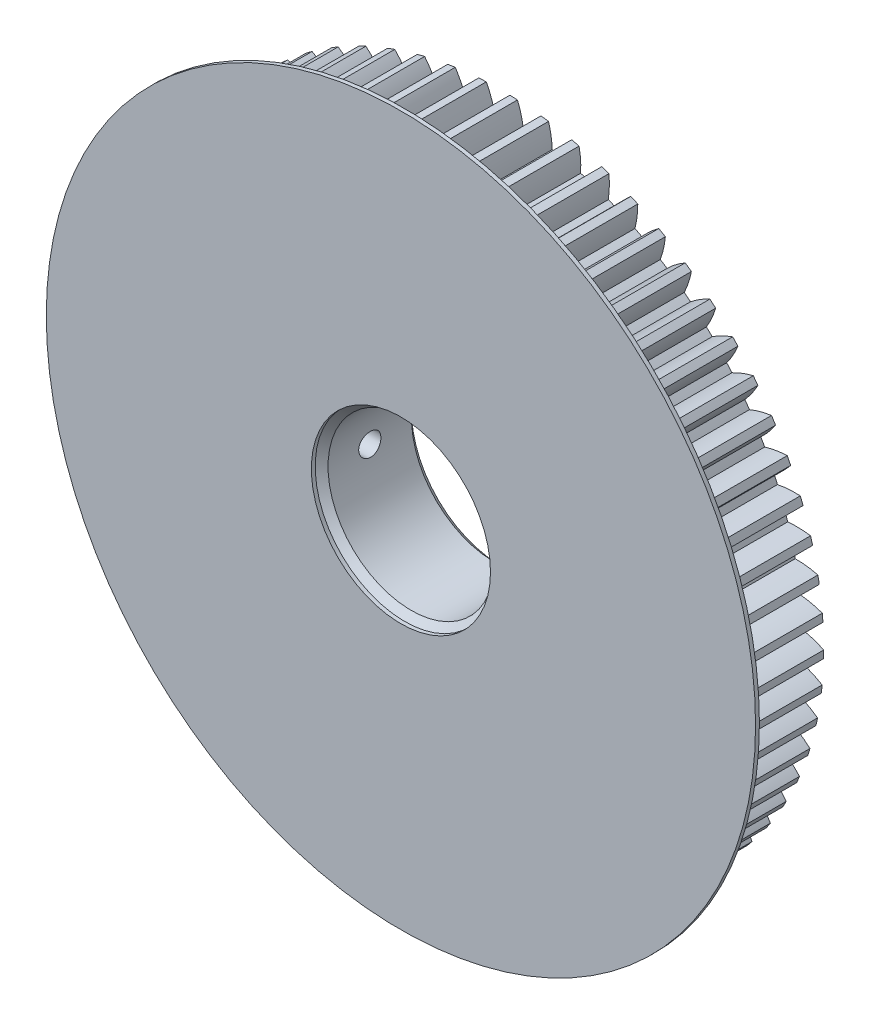
from build123d import *

# Parameters (mm, degrees)
SKETCH2_R                   = 50.25
GEAR_OUTSIDE_DIAMETER_DEPTH = 15
GEAR_TOOTH_CUT_DEPTH        = 73.630055762
GEAR_TEETH_COUNT            = 65
SKETCH3_R                   = 46.875
GEAR_DEDENDUM_CIRCLE_DEPTH  = 15
SKETCH4_R                   = 12.95
CUT_EXTRUDE1_DEPTH          = 73.629886766
CHAMFER1_SIZE               = 1
F_8_32_TAPPED_HOLE1_REACH   = 114.972
F_8_32_TAPPED_HOLE1_BORE_R  = 1.7272
SKETCH6_R                   = 55.234062962
SKETCH6_R_2                 = 13.95
BOSS_EXTRUDE1_DEPTH         = 0.6


with BuildPart() as part:
    # Sketch2 → gear outside diameter (new body)
    with BuildSketch(Plane.XY):
        Circle(SKETCH2_R)
    extrude(amount=GEAR_OUTSIDE_DIAMETER_DEPTH)

    # Sketch1 → gear tooth cut (cut, through all)
    with BuildSketch(Plane.XY):
        with BuildLine():
            Line((0, 45.810015263), (0, 46.875))
            ThreePointArc((0, 46.875), (-0.434136612, 46.872989561), (-0.868235984, 46.866958417))
            Line((-0.868235984, 46.866958417), (-0.848509946, 45.802156383))
            ThreePointArc((-0.848509946, 45.802156383), (-1.391693129, 48.060225078), (-2.301023276, 50.197288691))
            ThreePointArc((-2.301023276, 50.197288691), (-0.465394448, 50.24784481), (1.37085589, 50.231297556))
            ThreePointArc((1.37085589, 50.231297556), (0.501265219, 48.077757617), (0, 45.810015263))
        make_face()
    gear_tooth_cut = extrude(amount=GEAR_TOOTH_CUT_DEPTH, mode=Mode.SUBTRACT)

    # gear teeth: gear tooth cut ×65 about axis
    gear_teeth_axis = Axis((0, 0, 0), (0, 0, 1))
    for i in range(1, GEAR_TEETH_COUNT):
        add(gear_tooth_cut.rotate(gear_teeth_axis, i * 360 / GEAR_TEETH_COUNT), mode=Mode.SUBTRACT)

    # Sketch3 → gear dedendum circle (add)
    with BuildSketch(Plane.XY):
        Circle(SKETCH3_R)
    extrude(amount=GEAR_DEDENDUM_CIRCLE_DEPTH)

    # Sketch4 → Cut-Extrude1 (cut, through all)
    with BuildSketch(Plane.XY.offset(15)):
        Circle(SKETCH4_R)
    extrude(amount=-CUT_EXTRUDE1_DEPTH, mode=Mode.SUBTRACT)

    # Chamfer1
    chamfer1_edges = [part.edges().sort_by_distance(p)[0] for p in [
        (-12.95, 0, 0),
        (-12.95, 0, 15),
    ]]
    chamfer(chamfer1_edges, length=CHAMFER1_SIZE)

    # #8-32 Tapped Hole1 bore (on position points) → #8-32 Tapped Hole1 (cut, up to next)
    with BuildSketch(Plane(origin=(-50.243092483, -0.833161288, 7.5), x_dir=(0.016580324144, -0.999862536978, 0), z_dir=(-0.999862536978, -0.016580324144, 0)), mode=Mode.PRIVATE) as f_8_32_tapped_hole1_sk1:
        Circle(F_8_32_TAPPED_HOLE1_BORE_R)
    f_8_32_tapped_hole1_tool1 = extrude(f_8_32_tapped_hole1_sk1.sketch, amount=-F_8_32_TAPPED_HOLE1_REACH, mode=Mode.PRIVATE) & part.part
    add(f_8_32_tapped_hole1_tool1.solids().sort_by_distance((-50.243092, -0.833161, 7.5))[0], mode=Mode.SUBTRACT)

    # Sketch6 → Boss-Extrude1 (add)
    with BuildSketch(Plane.XY.offset(15)):
        Circle(SKETCH6_R)
        Circle(SKETCH6_R_2, mode=Mode.SUBTRACT)
    extrude(amount=BOSS_EXTRUDE1_DEPTH)


solid = part.part
